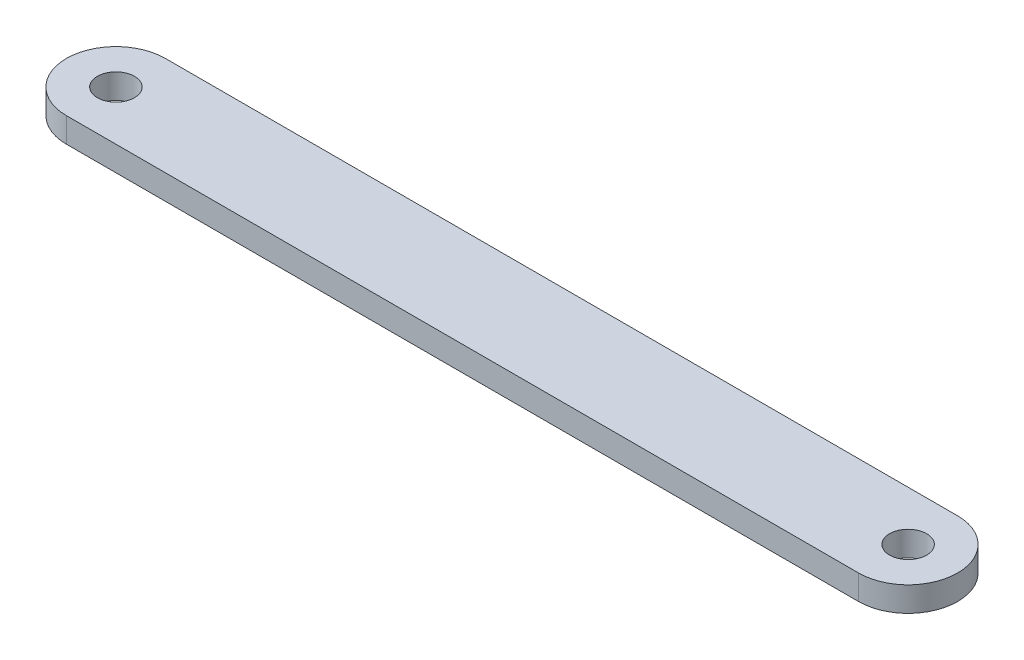
from build123d import *

# Parameters (mm, degrees)
SKETCH1_R           = 4.7625
BOSS_EXTRUDE1_DEPTH = 6.35


with BuildPart() as part:
    # Sketch1 → Boss-Extrude1 (new body)
    with BuildSketch(Plane(origin=(0, 0, 0), x_dir=(1, 0, 0), z_dir=(0, 1, 0))):
        with BuildLine():
            Line((-101.6, 12.7), (101.6, 12.7))
            ThreePointArc((101.6, 12.7), (114.3, 0), (101.6, -12.7))
            Line((101.6, -12.7), (-101.6, -12.7))
            ThreePointArc((-101.6, -12.7), (-114.3, 0), (-101.6, 12.7))
        make_face()
        with Locations((-101.6, 0)):
            Circle(SKETCH1_R, mode=Mode.SUBTRACT)
        with Locations((101.6, 0)):
            Circle(SKETCH1_R, mode=Mode.SUBTRACT)
    extrude(amount=BOSS_EXTRUDE1_DEPTH)


solid = part.part
